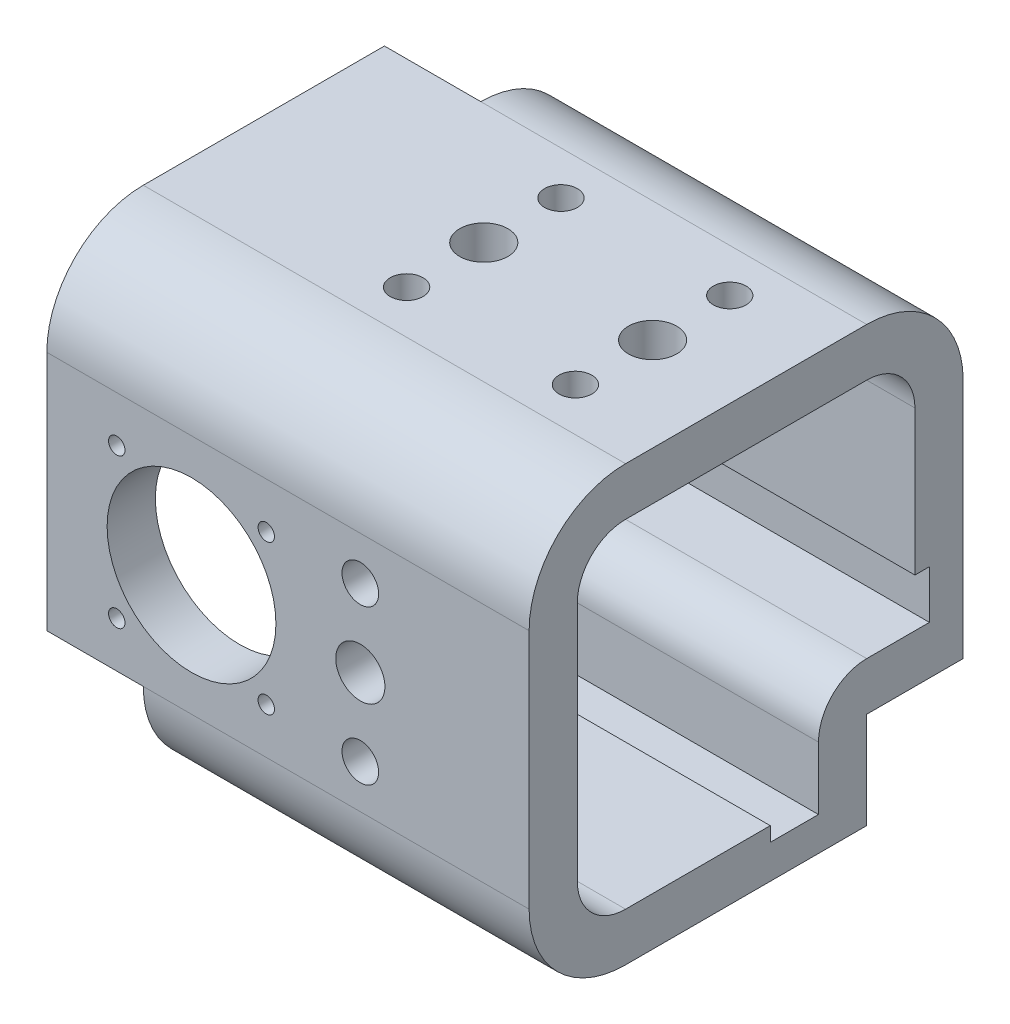
from build123d import *

# Parameters (mm, degrees)
BOSS_EXTRUDE1_DEPTH      = 70
BOSS_EXTRUDE1_DEPTH_BACK = 30
CUT_EXTRUDE1_REACH       = 92
SKETCH3_R                = 1.7
SKETCH3_R_2              = 17.5
SKETCH3_R_3              = 5.1
SKETCH3_R_4              = 3.8
CUT_EXTRUDE2_REACH       = 92
SKETCH4_R                = 5
SKETCH4_R_2              = 3.4
SKETCH5_W                = 20
SKETCH5_H                = 20
CUT_EXTRUDE3_DEPTH       = 1
CUT_EXTRUDE3_DEPTH_BACK  = 91
SKETCH6_W                = 20
SKETCH6_H                = 20
CUT_EXTRUDE4_DEPTH       = 91
SKETCH7_W                = 3
SKETCH7_H                = 20
SKETCH7_W_2              = 20
SKETCH7_H_2              = 3
CUT_EXTRUDE5_DEPTH       = 81
BOSS_EXTRUDE2_DEPTH      = 80


with BuildPart() as part:
    # Sketch2 → Boss-Extrude1 (new body, two sides)
    with BuildSketch(Plane(origin=(0, 0, 0), x_dir=(0, 0, -1), z_dir=(1, 0, 0))) as boss_extrude1_sk:
        with BuildLine():
            Line((3434.65392981, 139.447907294), (3384.65392981, 139.447907294))
            ThreePointArc((3384.65392981, 139.447907294), (3370.511794186, 133.590042917), (3364.65392981, 119.447907294))
            Line((3364.65392981, 119.447907294), (3364.65392981, 69.447907294))
            ThreePointArc((3364.65392981, 69.447907294), (3370.511794186, 55.30577167), (3384.65392981, 49.447907294))
            Line((3384.65392981, 49.447907294), (3434.65392981, 49.447907294))
            ThreePointArc((3434.65392981, 49.447907294), (3448.796065434, 55.30577167), (3454.65392981, 69.447907294))
            Line((3454.65392981, 69.447907294), (3454.65392981, 119.447907294))
            ThreePointArc((3454.65392981, 119.447907294), (3448.796065434, 133.590042917), (3434.65392981, 139.447907294))
        make_face()
        with BuildLine():
            Line((3434.65392981, 129.447907294), (3384.65392981, 129.447907294))
            ThreePointArc((3384.65392981, 129.447907294), (3377.582861998, 126.518975106), (3374.65392981, 119.447907294))
            Line((3374.65392981, 119.447907294), (3374.65392981, 69.447907294))
            ThreePointArc((3374.65392981, 69.447907294), (3377.582861998, 62.376839482), (3384.65392981, 59.447907294))
            Line((3384.65392981, 59.447907294), (3434.65392981, 59.447907294))
            ThreePointArc((3434.65392981, 59.447907294), (3441.724997622, 62.376839482), (3444.65392981, 69.447907294))
            Line((3444.65392981, 69.447907294), (3444.65392981, 119.447907294))
            ThreePointArc((3444.65392981, 119.447907294), (3441.724997622, 126.518975106), (3434.65392981, 129.447907294))
        make_face(mode=Mode.SUBTRACT)
    extrude(amount=BOSS_EXTRUDE1_DEPTH)
    extrude(boss_extrude1_sk.sketch, amount=-BOSS_EXTRUDE1_DEPTH_BACK)

    # Sketch3 → Cut-Extrude1 (cut, up to next)
    with BuildSketch(Plane.XY.offset(-3364.65392981), mode=Mode.PRIVATE) as cut_extrude1_sk1:
        with Locations((15.499999999, 78.947907294)):
            Circle(SKETCH3_R)
    cut_extrude1_tool1 = extrude(cut_extrude1_sk1.sketch, amount=-CUT_EXTRUDE1_REACH, mode=Mode.PRIVATE) & part.part
    add(cut_extrude1_tool1.solids().sort_by_distance((15.5, 78.947907, -3364.65393))[0], mode=Mode.SUBTRACT)
    # Sketch3 → Cut-Extrude1 (cut, up to next)
    with BuildSketch(Plane.XY.offset(-3364.65392981), mode=Mode.PRIVATE) as cut_extrude1_sk2:
        with Locations((15.499999999, 109.947907294)):
            Circle(SKETCH3_R)
    cut_extrude1_tool2 = extrude(cut_extrude1_sk2.sketch, amount=-CUT_EXTRUDE1_REACH, mode=Mode.PRIVATE) & part.part
    add(cut_extrude1_tool2.solids().sort_by_distance((15.5, 109.947907, -3364.65393))[0], mode=Mode.SUBTRACT)
    # Sketch3 → Cut-Extrude1 (cut, up to next)
    with BuildSketch(Plane.XY.offset(-3364.65392981), mode=Mode.PRIVATE) as cut_extrude1_sk3:
        with Locations((-15.500000001, 109.947907294)):
            Circle(SKETCH3_R)
    cut_extrude1_tool3 = extrude(cut_extrude1_sk3.sketch, amount=-CUT_EXTRUDE1_REACH, mode=Mode.PRIVATE) & part.part
    add(cut_extrude1_tool3.solids().sort_by_distance((-15.5, 109.947907, -3364.65393))[0], mode=Mode.SUBTRACT)
    # Sketch3 → Cut-Extrude1 (cut, up to next)
    with BuildSketch(Plane.XY.offset(-3364.65392981), mode=Mode.PRIVATE) as cut_extrude1_sk4:
        with Locations((-15.500000001, 78.947907294)):
            Circle(SKETCH3_R)
    cut_extrude1_tool4 = extrude(cut_extrude1_sk4.sketch, amount=-CUT_EXTRUDE1_REACH, mode=Mode.PRIVATE) & part.part
    add(cut_extrude1_tool4.solids().sort_by_distance((-15.5, 78.947907, -3364.65393))[0], mode=Mode.SUBTRACT)
    # Sketch3 → Cut-Extrude1 (cut, up to next)
    with BuildSketch(Plane.XY.offset(-3364.65392981), mode=Mode.PRIVATE) as cut_extrude1_sk5:
        with Locations((0, 94.447907293)):
            Circle(SKETCH3_R_2)
    cut_extrude1_tool5 = extrude(cut_extrude1_sk5.sketch, amount=-CUT_EXTRUDE1_REACH, mode=Mode.PRIVATE) & part.part
    add(cut_extrude1_tool5.solids().sort_by_distance((0, 94.447907, -3364.65393))[0], mode=Mode.SUBTRACT)
    # Sketch3 → Cut-Extrude1 (cut, up to next)
    with BuildSketch(Plane.XY.offset(-3364.65392981), mode=Mode.PRIVATE) as cut_extrude1_sk6:
        with Locations((34.999999999, 94.447907294)):
            Circle(SKETCH3_R_3)
    cut_extrude1_tool6 = extrude(cut_extrude1_sk6.sketch, amount=-CUT_EXTRUDE1_REACH, mode=Mode.PRIVATE) & part.part
    add(cut_extrude1_tool6.solids().sort_by_distance((35, 94.447907, -3364.65393))[0], mode=Mode.SUBTRACT)
    # Sketch3 → Cut-Extrude1 (cut, up to next)
    with BuildSketch(Plane.XY.offset(-3364.65392981), mode=Mode.PRIVATE) as cut_extrude1_sk7:
        with Locations((35, 78.447907293)):
            Circle(SKETCH3_R_4)
    cut_extrude1_tool7 = extrude(cut_extrude1_sk7.sketch, amount=-CUT_EXTRUDE1_REACH, mode=Mode.PRIVATE) & part.part
    add(cut_extrude1_tool7.solids().sort_by_distance((35, 78.447907, -3364.65393))[0], mode=Mode.SUBTRACT)
    # Sketch3 → Cut-Extrude1 (cut, up to next)
    with BuildSketch(Plane.XY.offset(-3364.65392981), mode=Mode.PRIVATE) as cut_extrude1_sk8:
        with Locations((35, 110.447907293)):
            Circle(SKETCH3_R_4)
    cut_extrude1_tool8 = extrude(cut_extrude1_sk8.sketch, amount=-CUT_EXTRUDE1_REACH, mode=Mode.PRIVATE) & part.part
    add(cut_extrude1_tool8.solids().sort_by_distance((35, 110.447907, -3364.65393))[0], mode=Mode.SUBTRACT)

    # Sketch4 → Cut-Extrude2 (cut, up to next)
    with BuildSketch(Plane(origin=(0, 139.447907294, 0), x_dir=(1, 0, 0), z_dir=(0, 1, 0)), mode=Mode.PRIVATE) as cut_extrude2_sk1:
        with Locations((15.6, 3409.65392981)):
            Circle(SKETCH4_R)
    cut_extrude2_tool1 = extrude(cut_extrude2_sk1.sketch, amount=-CUT_EXTRUDE2_REACH, mode=Mode.PRIVATE) & part.part
    add(cut_extrude2_tool1.solids().sort_by_distance((15.6, 139.447907, -3409.65393))[0], mode=Mode.SUBTRACT)
    # Sketch4 → Cut-Extrude2 (cut, up to next)
    with BuildSketch(Plane(origin=(0, 139.447907294, 0), x_dir=(1, 0, 0), z_dir=(0, 1, 0)), mode=Mode.PRIVATE) as cut_extrude2_sk2:
        with Locations((50.6, 3409.65392981)):
            Circle(SKETCH4_R)
    cut_extrude2_tool2 = extrude(cut_extrude2_sk2.sketch, amount=-CUT_EXTRUDE2_REACH, mode=Mode.PRIVATE) & part.part
    add(cut_extrude2_tool2.solids().sort_by_distance((50.6, 139.447907, -3409.65393))[0], mode=Mode.SUBTRACT)
    # Sketch4 → Cut-Extrude2 (cut, up to next)
    with BuildSketch(Plane(origin=(0, 139.447907294, 0), x_dir=(1, 0, 0), z_dir=(0, 1, 0)), mode=Mode.PRIVATE) as cut_extrude2_sk3:
        with Locations((50.6, 3425.65392981)):
            Circle(SKETCH4_R_2)
    cut_extrude2_tool3 = extrude(cut_extrude2_sk3.sketch, amount=-CUT_EXTRUDE2_REACH, mode=Mode.PRIVATE) & part.part
    add(cut_extrude2_tool3.solids().sort_by_distance((50.6, 139.447907, -3425.65393))[0], mode=Mode.SUBTRACT)
    # Sketch4 → Cut-Extrude2 (cut, up to next)
    with BuildSketch(Plane(origin=(0, 139.447907294, 0), x_dir=(1, 0, 0), z_dir=(0, 1, 0)), mode=Mode.PRIVATE) as cut_extrude2_sk4:
        with Locations((50.6, 3393.65392981)):
            Circle(SKETCH4_R_2)
    cut_extrude2_tool4 = extrude(cut_extrude2_sk4.sketch, amount=-CUT_EXTRUDE2_REACH, mode=Mode.PRIVATE) & part.part
    add(cut_extrude2_tool4.solids().sort_by_distance((50.6, 139.447907, -3393.65393))[0], mode=Mode.SUBTRACT)
    # Sketch4 → Cut-Extrude2 (cut, up to next)
    with BuildSketch(Plane(origin=(0, 139.447907294, 0), x_dir=(1, 0, 0), z_dir=(0, 1, 0)), mode=Mode.PRIVATE) as cut_extrude2_sk5:
        with Locations((15.6, 3425.65392981)):
            Circle(SKETCH4_R_2)
    cut_extrude2_tool5 = extrude(cut_extrude2_sk5.sketch, amount=-CUT_EXTRUDE2_REACH, mode=Mode.PRIVATE) & part.part
    add(cut_extrude2_tool5.solids().sort_by_distance((15.6, 139.447907, -3425.65393))[0], mode=Mode.SUBTRACT)
    # Sketch4 → Cut-Extrude2 (cut, up to next)
    with BuildSketch(Plane(origin=(0, 139.447907294, 0), x_dir=(1, 0, 0), z_dir=(0, 1, 0)), mode=Mode.PRIVATE) as cut_extrude2_sk6:
        with Locations((15.6, 3393.65392981)):
            Circle(SKETCH4_R_2)
    cut_extrude2_tool6 = extrude(cut_extrude2_sk6.sketch, amount=-CUT_EXTRUDE2_REACH, mode=Mode.PRIVATE) & part.part
    add(cut_extrude2_tool6.solids().sort_by_distance((15.6, 139.447907, -3393.65393))[0], mode=Mode.SUBTRACT)

    # Sketch5 → Cut-Extrude3 (cut, two sides)
    with BuildSketch(Plane.XY.offset(-3364.65392981)) as cut_extrude3_sk:
        with Locations((-20, 59.447907294)):
            Rectangle(SKETCH5_W, SKETCH5_H)
    extrude(amount=CUT_EXTRUDE3_DEPTH, mode=Mode.SUBTRACT)
    extrude(cut_extrude3_sk.sketch, amount=-CUT_EXTRUDE3_DEPTH_BACK, mode=Mode.SUBTRACT)

    # Sketch6 → Cut-Extrude4 (cut, through all)
    with BuildSketch(Plane(origin=(0, 139.447907294, 0), x_dir=(1, 0, 0), z_dir=(0, 1, 0))):
        with Locations((-20, 3444.65392981)):
            Rectangle(SKETCH6_W, SKETCH6_H)
    extrude(amount=-CUT_EXTRUDE4_DEPTH, mode=Mode.SUBTRACT)

    # Sketch7 → Cut-Extrude5 (cut, through all)
    with BuildSketch(Plane.ZY.offset(10)):
        with BuildLine():
            Line((-3447.65392981, 69.447907294), (-3454.65392981, 69.447907294))
            ThreePointArc((-3454.65392981, 69.447907294), (-3448.796065434, 55.30577167), (-3434.65392981, 49.447907294))
            Line((-3434.65392981, 49.447907294), (-3434.65392981, 56.447907294))
            Line((-3434.65392981, 56.447907294), (-3434.65392981, 59.447907294))
            ThreePointArc((-3434.65392981, 59.447907294), (-3441.724997622, 62.376839482), (-3444.65392981, 69.447907294))
            Line((-3444.65392981, 69.447907294), (-3447.65392981, 69.447907294))
        make_face()
        with Locations((-3446.15392981, 79.447907294)):
            Rectangle(SKETCH7_W, SKETCH7_H)
        with Locations((-3424.65392981, 57.947907294)):
            Rectangle(SKETCH7_W_2, SKETCH7_H_2)
    extrude(amount=-CUT_EXTRUDE5_DEPTH, mode=Mode.SUBTRACT)

    # Sketch8 → Boss-Extrude2 (add)
    with BuildSketch(Plane.ZY.offset(10)):
        with BuildLine():
            Line((-3454.65392981, 79.447907294), (-3434.65392981, 79.447907294))
            ThreePointArc((-3434.65392981, 79.447907294), (-3427.582861998, 76.518975106), (-3424.65392981, 69.447907294))
            Line((-3424.65392981, 69.447907294), (-3424.65392981, 49.447907294))
            Line((-3424.65392981, 49.447907294), (-3434.65392981, 49.447907294))
            Line((-3434.65392981, 49.447907294), (-3434.65392981, 69.447907294))
            Line((-3434.65392981, 69.447907294), (-3454.65392981, 69.447907294))
            Line((-3454.65392981, 69.447907294), (-3454.65392981, 79.447907294))
        make_face()
    extrude(amount=-BOSS_EXTRUDE2_DEPTH)


solid = part.part
